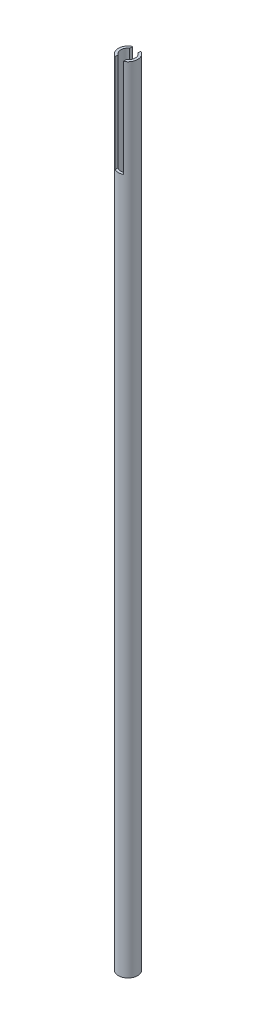
from build123d import *

# Parameters (mm, degrees)
SKETCH1_R           = 10.71245
SKETCH1_R_2         = 7.9375
BOSS_EXTRUDE1_DEPTH = 879.475
SKETCH2_W           = 9.144
SKETCH2_H           = 21.4249
CUT_EXTRUDE1_DEPTH  = 108.585


with BuildPart() as part:
    # Sketch1 → Boss-Extrude1 (new body)
    with BuildSketch(Plane(origin=(0, 0, 0), x_dir=(1, 0, 0), z_dir=(0, 1, 0))):
        Circle(SKETCH1_R)
        Circle(SKETCH1_R_2, mode=Mode.SUBTRACT)
    extrude(amount=BOSS_EXTRUDE1_DEPTH)

    # Sketch2 → Cut-Extrude1 (cut)
    with BuildSketch(Plane(origin=(0, 879.475, 0), x_dir=(1, 0, 0), z_dir=(0, 1, 0))):
        Rectangle(SKETCH2_W, SKETCH2_H)
    extrude(amount=-CUT_EXTRUDE1_DEPTH, mode=Mode.SUBTRACT)


solid = part.part
